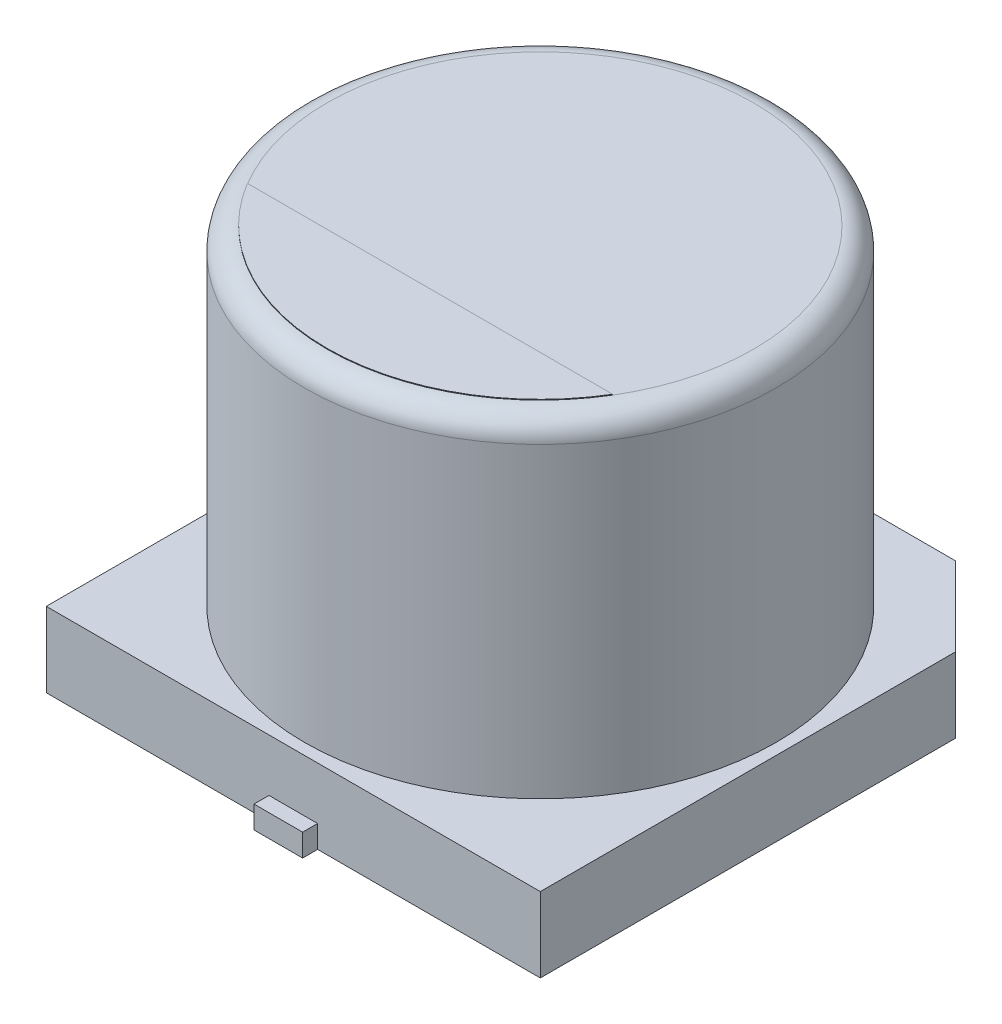
from build123d import *

# Parameters (mm, degrees)
BOSS_EXTRUDE1_DEPTH = 1
SKETCH3_R           = 3.15
BOSS_EXTRUDE2_DEPTH = 5.4
FILLET1_R           = 0.3
SKETCH4_W           = 0.65
SKETCH4_H           = 2.6
BOSS_EXTRUDE3_DEPTH = 0.3
BOSS_EXTRUDE4_DEPTH = 0.01


with BuildPart() as part:
    # Sketch2 → Boss-Extrude1 (new body)
    with BuildSketch(Plane(origin=(0, 0, 0), x_dir=(1, 0, 0), z_dir=(0, 1, 0))):
        Polygon((3.3, -3.3), (-3.3, -3.3), (-3.3, 2.25), (-2.25, 3.3), (2.25, 3.3), (3.3, 2.25), align=None)
    extrude(amount=BOSS_EXTRUDE1_DEPTH)

    # Sketch3 → Boss-Extrude2 (add)
    with BuildSketch(Plane(origin=(0, 0, 0), x_dir=(1, 0, 0), z_dir=(0, 1, 0))):
        Circle(SKETCH3_R)
    extrude(amount=BOSS_EXTRUDE2_DEPTH)

    # Fillet1
    fillet1_edges = [part.edges().sort_by_distance(p)[0] for p in [
        (-3.15, 5.4, 0),
    ]]
    fillet(fillet1_edges, radius=FILLET1_R)

    # Sketch4 → Boss-Extrude3 (add)
    with BuildSketch(Plane(origin=(0, 0, 0), x_dir=(1, 0, 0), z_dir=(0, 1, 0))):
        with Locations((0, 2.2)):
            Rectangle(SKETCH4_W, SKETCH4_H)
        with Locations((0, -2.2)):
            Rectangle(SKETCH4_W, SKETCH4_H)
    extrude(amount=BOSS_EXTRUDE3_DEPTH)

    # Sketch5 → Boss-Extrude4 (add)
    with BuildSketch(Plane(origin=(0, 5.4, 0), x_dir=(1, 0, 0), z_dir=(0, 1, 0))):
        with BuildLine():
            Line((-2.439908144, -1.472870752), (2.439908144, -1.472870752))
            ThreePointArc((2.439908144, -1.472870752), (0, -2.85), (-2.439908144, -1.472870752))
        make_face()
    extrude(amount=BOSS_EXTRUDE4_DEPTH)


solid = part.part
